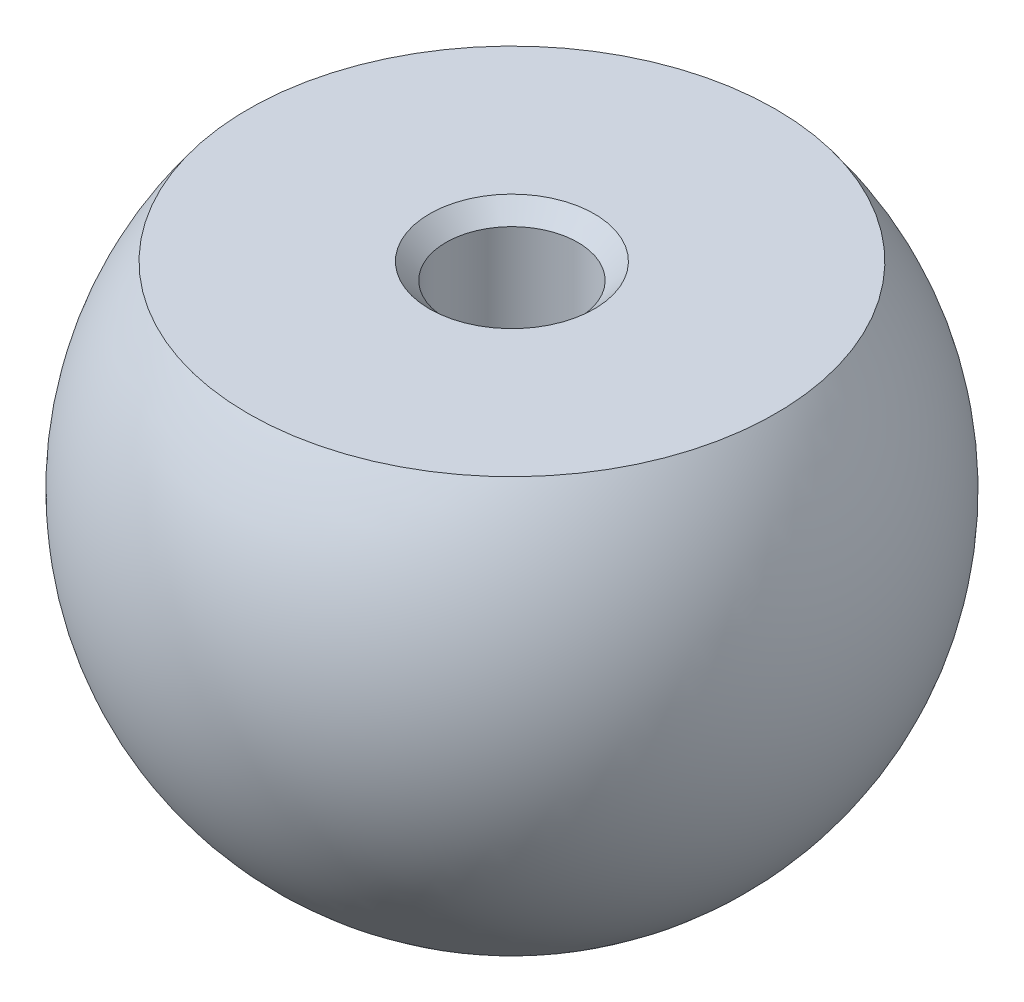
from build123d import *

# Parameters (mm, degrees)
SKETCH2_R          = 4
CUT_EXTRUDE1_DEPTH = 20
CHAMFER1_SIZE      = 10
CHAMFER1_SIZE2     = 0.174550649
CHAMFER2_SIZE      = 1


with BuildPart() as part:
    # Sketch1 → Revolve2 (revolve)
    with BuildSketch(Plane(origin=(0, 0, 0), x_dir=(0, 0, -1), z_dir=(1, 0, 0))):
        with BuildLine():
            Line((0, 12), (16, 12))
            ThreePointArc((16, 12), (17.88854382, -8.94427191), (0, -20))
            Line((0, -20), (0, 12))
        make_face()
    revolve(axis=Axis((0, -20, 0), (0, 1, 0)))

    # Sketch2 → Cut-Extrude1 (cut)
    with BuildSketch(Plane(origin=(0, 12, 0), x_dir=(1, 0, 0), z_dir=(0, 1, 0))):
        Circle(SKETCH2_R)
    extrude(amount=-CUT_EXTRUDE1_DEPTH, mode=Mode.SUBTRACT)

    # Chamfer1
    chamfer1_edges = [part.edges().sort_by_distance(p)[0] for p in [
        (-4, -8, 0),
    ]]
    chamfer1_side = [part.faces().sort_by_distance(p)[0] for p in [
        (-4, 2, 0),
    ]]
    chamfer(chamfer1_edges, length=CHAMFER1_SIZE, length2=CHAMFER1_SIZE2, reference=chamfer1_side[0])

    # Chamfer2
    chamfer2_edges = [part.edges().sort_by_distance(p)[0] for p in [
        (-4, 12, 0),
    ]]
    chamfer(chamfer2_edges, length=CHAMFER2_SIZE)


solid = part.part
